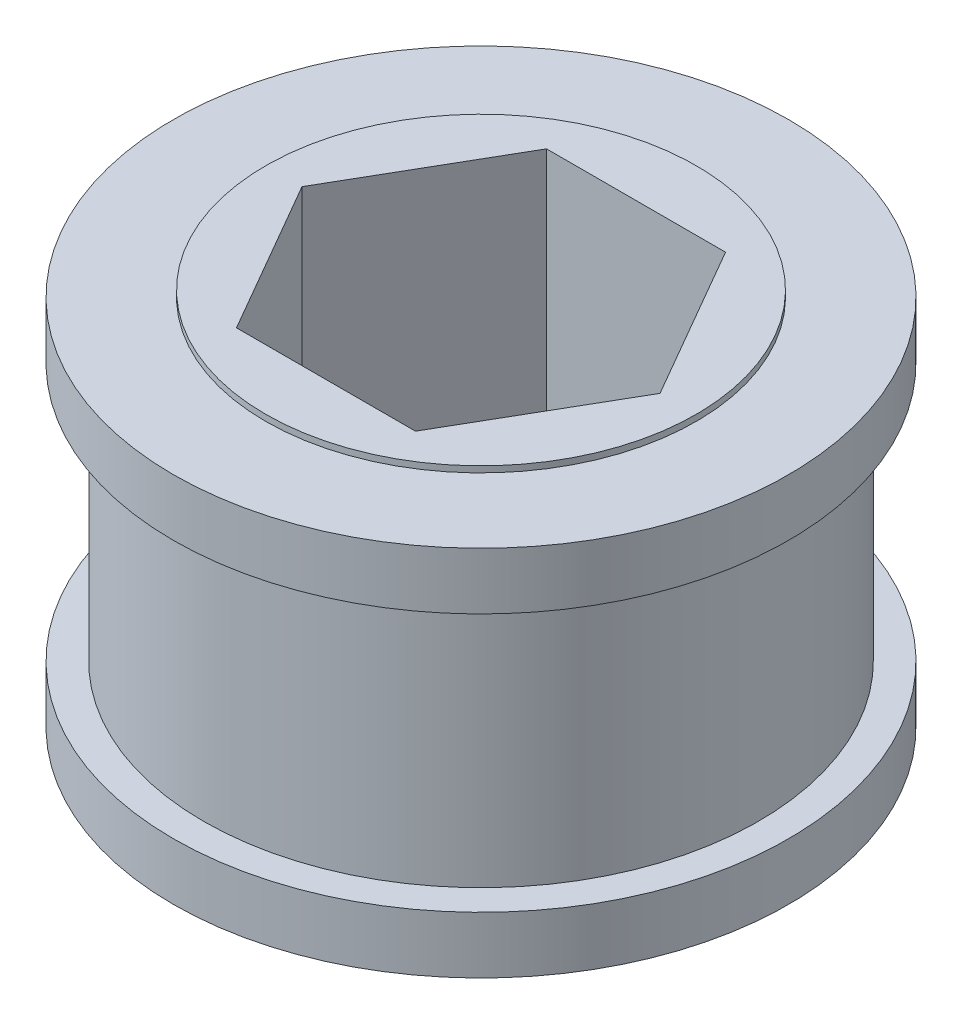
from build123d import *

# Parameters (mm, degrees)
CUT_EXTRUDE1_DEPTH      = 1
CUT_EXTRUDE1_DEPTH_BACK = 16.875


with BuildPart() as part:
    # Sketch2 → Revolve1 (revolve)
    with BuildSketch(Plane(origin=(0, 0, 0), x_dir=(0, 0, -1), z_dir=(1, 0, 0))):
        Polygon((2.54, -3.2131), (8.89, -3.2131), (8.89, -3.4671), (12.7, -3.4671), (12.7, -5.8166), (11.4554, -5.8166), (11.4554, -16.4846), (12.7, -16.4846), (12.7, -18.8341), (8.89, -18.8341), (8.89, -19.0881), (2.54, -19.0881), align=None)
    revolve(axis=Axis((0, 55, 0), (0, -1, 0)))

    # Sketch3 → Cut-Extrude1 (cut, two sides)
    with BuildSketch(Plane(origin=(0, -3.2131, 0), x_dir=(1, 0, 0), z_dir=(0, 1, 0))) as cut_extrude1_sk:
        Polygon((3.695503603, 6.4008), (-3.695503603, 6.4008), (-7.391007206, 0), (-3.695503603, -6.4008), (3.695503603, -6.4008), (7.391007206, 0), align=None)
    extrude(amount=CUT_EXTRUDE1_DEPTH, mode=Mode.SUBTRACT)
    extrude(cut_extrude1_sk.sketch, amount=-CUT_EXTRUDE1_DEPTH_BACK, mode=Mode.SUBTRACT)


solid = part.part
